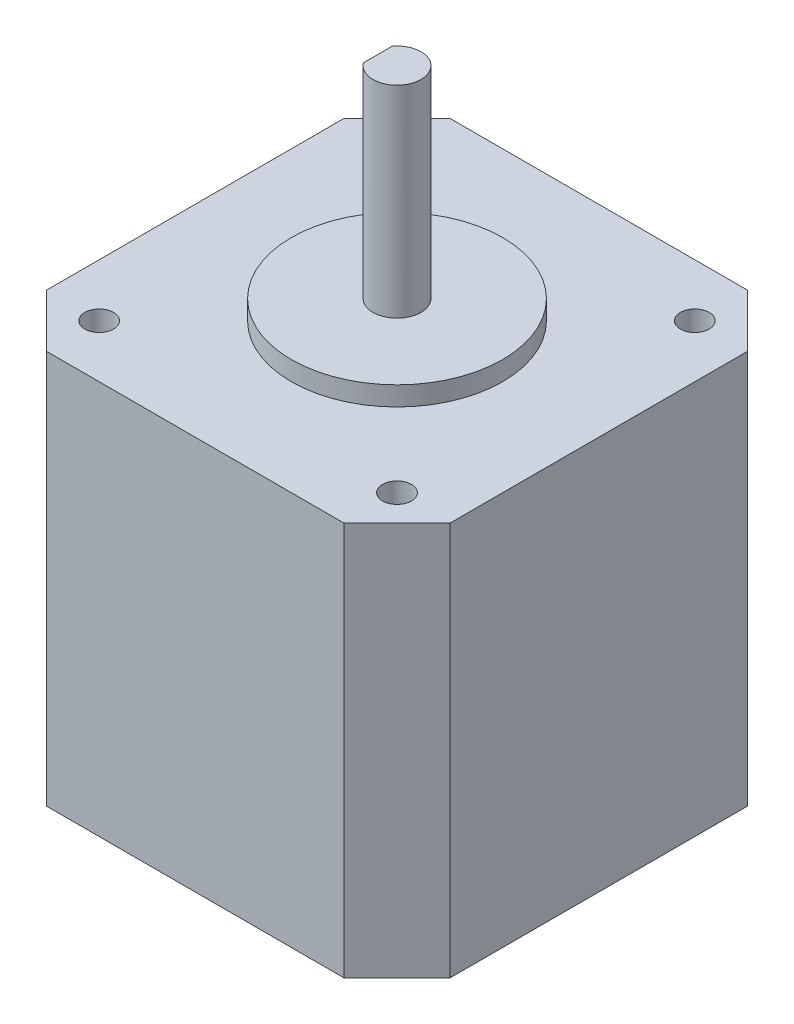
from build123d import *

# Parameters (mm, degrees)
BOSS_EXTRUDE1_DEPTH = 11.5
BOSS_EXTRUDE2_DEPTH = 10
SKETCH4_R           = 1.5
BOSS_EXTRUDE3_DEPTH = 8
SKETCH5_R           = 11
BOSS_EXTRUDE4_DEPTH = 2
SKETCH6_R           = 2.5
BOSS_EXTRUDE5_DEPTH = 21
CUT_EXTRUDE1_DEPTH  = 18


with BuildPart() as part:
    # Sketch1 → Boss-Extrude1 (new body, symmetric)
    with BuildSketch(Plane(origin=(0, 0, 0), x_dir=(1, 0, 0), z_dir=(0, 1, 0))):
        Polygon((-15.5, -21), (15.5, -21), (21, -15.5), (21, 15.5), (15.5, 21), (-15.5, 21), (-21, 15.5), (-21, -15.5), align=None)
    extrude(amount=BOSS_EXTRUDE1_DEPTH, both=True)

    # Sketch3 → Boss-Extrude2 (add)
    with BuildSketch(Plane.XZ.offset(11.5)):
        Polygon((15.5, 21), (-15.5, 21), (-21, 15.5), (-21, -15.5), (-15.5, -21), (15.5, -21), (21, -15.5), (21, 15.5), align=None)
    extrude(amount=BOSS_EXTRUDE2_DEPTH)

    # Sketch4 → Boss-Extrude3 (add)
    with BuildSketch(Plane(origin=(0, 11.5, 0), x_dir=(1, 0, 0), z_dir=(0, 1, 0))):
        Polygon((-15.5, -21), (15.5, -21), (21, -15.5), (21, 15.5), (15.5, 21), (-15.5, 21), (-21, 15.5), (-21, -15.5), align=None)
        with Locations((-15.5, 15.5)):
            Circle(SKETCH4_R, mode=Mode.SUBTRACT)
        with Locations((15.5, 15.5)):
            Circle(SKETCH4_R, mode=Mode.SUBTRACT)
        with Locations((-15.5, -15.5)):
            Circle(SKETCH4_R, mode=Mode.SUBTRACT)
        with Locations((15.5, -15.5)):
            Circle(SKETCH4_R, mode=Mode.SUBTRACT)
    extrude(amount=BOSS_EXTRUDE3_DEPTH)

    # Sketch5 → Boss-Extrude4 (add)
    with BuildSketch(Plane(origin=(0, 19.5, 0), x_dir=(1, 0, 0), z_dir=(0, 1, 0))):
        Circle(SKETCH5_R)
    extrude(amount=BOSS_EXTRUDE4_DEPTH)

    # Sketch6 → Boss-Extrude5 (add)
    with BuildSketch(Plane(origin=(0, 21.5, 0), x_dir=(1, 0, 0), z_dir=(0, 1, 0))):
        Circle(SKETCH6_R)
    extrude(amount=BOSS_EXTRUDE5_DEPTH)

    # Sketch9 → Cut-Extrude1 (cut)
    with BuildSketch(Plane(origin=(0, 42.5, 0), x_dir=(1, 0, 0), z_dir=(0, 1, 0))):
        with BuildLine():
            Line((-2, 1.5), (-2, -1.5))
            ThreePointArc((-2, -1.5), (-2.5, 0), (-2, 1.5))
        make_face()
    extrude(amount=-CUT_EXTRUDE1_DEPTH, mode=Mode.SUBTRACT)


solid = part.part
